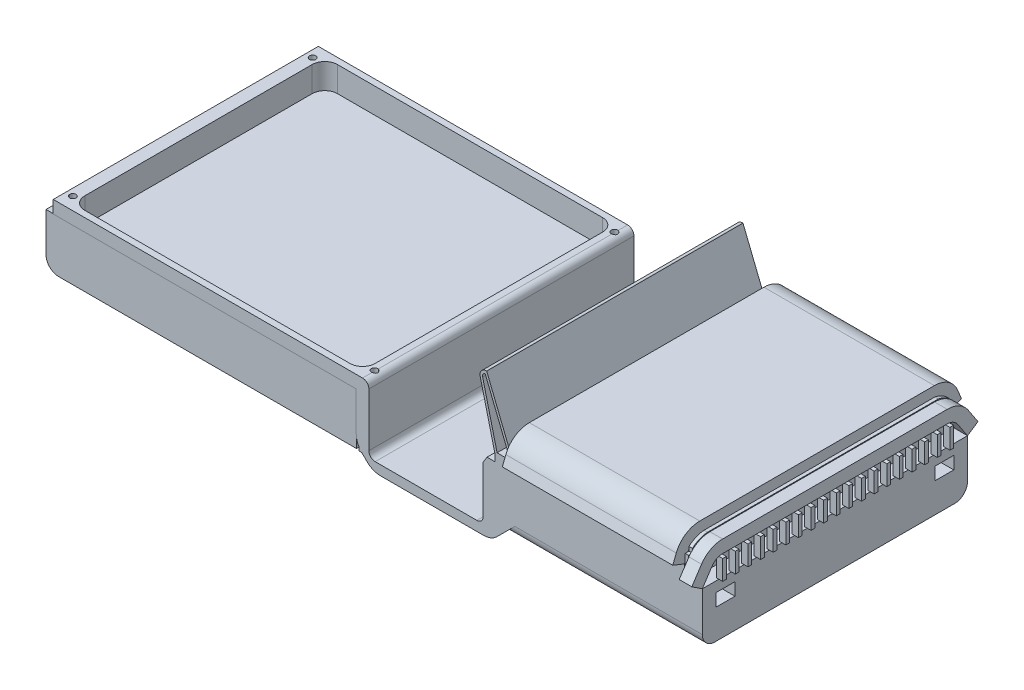
from build123d import *

# Parameters (mm, degrees)
EXTRUDE_THIN1_DEPTH       = 105
EXTRUDE_THIN2_DEPTH       = 135
SKETCH4_W                 = 210
SKETCH4_H                 = 41.464466094
BOSS_EXTRUDE1_DEPTH       = 272
SKETCH5_W                 = 99.443264673
SKETCH5_H                 = 42.373164523
CUT_EXTRUDE1_DEPTH        = 709
SKETCH6_W                 = 15
SKETCH6_H                 = 10
CUT_EXTRUDE3_DEPTH        = 10
BOSS_EXTRUDE12_DEPTH      = 203
EXTRUDE_THIN4_DEPTH       = 10
SKETCH11_W                = 2.941631748
SKETCH11_H                = 15.671312496
BOSS_EXTRUDE13_DEPTH      = 3
BOSS_EXTRUDE13_DEPTH_BACK = 2
SKETCH12_W                = 2.712469745
SKETCH12_H                = 25.887710017
BOSS_EXTRUDE16_DEPTH      = 210
CUT_EXTRUDE5_DEPTH        = 3
SKETCH14_W                = 2.712469745
SKETCH14_H                = 8.420422182
CUT_EXTRUDE6_DEPTH        = 3
CUT_EXTRUDE7_DEPTH        = 3
SKETCH16_W                = 2.712469745
SKETCH16_H                = 10.378010017
CUT_EXTRUDE8_DEPTH        = 3
BOSS_EXTRUDE17_DEPTH      = 209
FILLET1_R                 = 10
FILLET2_R                 = 10
SKETCH20_W                = 209.727383772
SKETCH20_H                = 41.060074577
BOSS_EXTRUDE18_DEPTH      = 246
FILLET3_R                 = 10
CUT_EXTRUDE9_DEPTH        = 20
FILLET4_R                 = 5
FILLET5_R                 = 5
FILLET6_R                 = 5
SKETCH24_R                = 2.5
CUT_EXTRUDE12_DEPTH       = 15


with BuildPart() as part:
    # Sketch1 → Extrude-Thin1 (new body, symmetric)
    with BuildSketch(Plane.XY):
        with BuildLine():
            Line((-242.134236503, 0), (7.865763497, 0))
            Line((7.865763497, 0), (7.865763497, -40.857864376))
            ThreePointArc((7.865763497, -40.857864376), (8.246365835, -42.771281538), (9.330229591, -44.393398282))
            Line((9.330229591, -44.393398282), (13.472365215, -48.535533906))
            ThreePointArc((13.472365215, -48.535533906), (15.094481959, -49.619397663), (17.007899121, -50))
            Line((17.007899121, -50), (98.723627874, -50))
            ThreePointArc((98.723627874, -50), (100.637045035, -49.619397663), (102.25916178, -48.535533906))
            Line((102.25916178, -48.535533906), (106.401297403, -44.393398282))
            ThreePointArc((106.401297403, -44.393398282), (107.48516116, -42.771281538), (107.865763497, -40.857864376))
            Line((107.865763497, -40.857864376), (107.865763497, 0))
            Line((107.865763497, 0), (257.865763497, 0))
            Line((257.865763497, 0), (257.865763497, -10))
            Line((257.865763497, -10), (117.865763497, -10))
            Line((117.865763497, -10), (117.865763497, -40.857864376))
            ThreePointArc((117.865763497, -40.857864376), (116.723956485, -46.598115862), (113.472365215, -51.464466094))
            Line((113.472365215, -51.464466094), (109.330229591, -55.606601718))
            ThreePointArc((109.330229591, -55.606601718), (104.463879359, -58.858192988), (98.723627874, -60))
            Line((98.723627874, -60), (17.007899121, -60))
            ThreePointArc((17.007899121, -60), (11.267647636, -58.858192988), (6.401297403, -55.606601718))
            Line((6.401297403, -55.606601718), (2.25916178, -51.464466094))
            ThreePointArc((2.25916178, -51.464466094), (-0.99242949, -46.598115862), (-2.134236503, -40.857864376))
            Line((-2.134236503, -40.857864376), (-2.134236503, -10))
            Line((-2.134236503, -10), (-242.134236503, -10))
            Line((-242.134236503, -10), (-242.134236503, 0))
        make_face()
    extrude(amount=EXTRUDE_THIN1_DEPTH, both=True)

    # Sketch4 → Boss-Extrude1 (add)
    with BuildSketch(Plane(origin=(0, 0, 0), x_dir=(0, 0, -1), z_dir=(1, 0, 0))):
        with Locations((0, -30.732233047)):
            Rectangle(SKETCH4_W, SKETCH4_H)
    extrude(amount=BOSS_EXTRUDE1_DEPTH)

    # Sketch5 → Cut-Extrude1 (cut)
    with BuildSketch(Plane.XY.offset(105)):
        with Locations((57.587395834, -31.186582261)):
            Rectangle(SKETCH5_W, SKETCH5_H)
    extrude(amount=-CUT_EXTRUDE1_DEPTH, mode=Mode.SUBTRACT)

    # Sketch6 → Cut-Extrude3 (cut)
    with BuildSketch(Plane(origin=(272, 0, 0), x_dir=(0, 0, -1), z_dir=(1, 0, 0))):
        with Locations((86.644406448, -23.03734916)):
            Rectangle(SKETCH6_W, SKETCH6_H)
        with Locations((-86.644406448, -23.03734916)):
            Rectangle(SKETCH6_W, SKETCH6_H)
    extrude(amount=-CUT_EXTRUDE3_DEPTH, mode=Mode.SUBTRACT)

    # Sketch9 → Boss-Extrude12 (add)
    with BuildSketch(Plane.XY.offset(105)):
        with BuildLine():
            Line((107.865763497, 0), (96.048468915, 47.715480872))
            ThreePointArc((96.048468915, 47.715480872), (96.964203042, 51.998873018), (100.901839983, 53.917474745))
            Line((100.901839983, 53.917474745), (101.189118197, 53.917474745))
            Line((101.189118197, 53.917474745), (122.865763497, 0))
            Line((122.865763497, 0), (107.865763497, 0))
        make_face()
        with BuildLine():
            Line((99.905994759, 51.747367373), (119.906116097, 2))
            Line((119.906116097, 2), (109.430863744, 2))
            Line((109.430863744, 2), (97.989817342, 48.196278421))
            ThreePointArc((97.989817342, 48.196278421), (98.261685442, 50.342109435), (99.905994759, 51.747367373))
        make_face(mode=Mode.SUBTRACT)
    extrude(amount=-BOSS_EXTRUDE12_DEPTH)

    # Sketch11 → Boss-Extrude13 (add, two sides)
    with BuildSketch(Plane(origin=(272, 0, 0), x_dir=(0, 0, -1), z_dir=(1, 0, 0))) as boss_extrude13_sk:
        with Locations((-90.432731373, -2.164343752)):
            Rectangle(SKETCH11_W, SKETCH11_H)
        with Locations((-80.432731373, -2.164343752)):
            Rectangle(SKETCH11_W, SKETCH11_H)
        with Locations((-70.432731373, -2.164343752)):
            Rectangle(SKETCH11_W, SKETCH11_H)
        with Locations((-60.432731373, -2.164343752)):
            Rectangle(SKETCH11_W, SKETCH11_H)
        with Locations((-50.432731373, -2.164343752)):
            Rectangle(SKETCH11_W, SKETCH11_H)
        with Locations((-40.432731373, -2.164343752)):
            Rectangle(SKETCH11_W, SKETCH11_H)
        with Locations((-30.432731373, -2.164343752)):
            Rectangle(SKETCH11_W, SKETCH11_H)
        with Locations((-20.432731373, -2.164343752)):
            Rectangle(SKETCH11_W, SKETCH11_H)
        with Locations((-10.432731373, -2.164343752)):
            Rectangle(SKETCH11_W, SKETCH11_H)
        with Locations((-0.432731373, -2.164343752)):
            Rectangle(SKETCH11_W, SKETCH11_H)
        with Locations((9.567268627, -2.164343752)):
            Rectangle(SKETCH11_W, SKETCH11_H)
        with Locations((19.567268627, -2.164343752)):
            Rectangle(SKETCH11_W, SKETCH11_H)
        with Locations((29.567268627, -2.164343752)):
            Rectangle(SKETCH11_W, SKETCH11_H)
        with Locations((39.567268627, -2.164343752)):
            Rectangle(SKETCH11_W, SKETCH11_H)
        with Locations((49.567268627, -2.164343752)):
            Rectangle(SKETCH11_W, SKETCH11_H)
        with Locations((59.567268627, -2.164343752)):
            Rectangle(SKETCH11_W, SKETCH11_H)
        with Locations((69.567268627, -2.164343752)):
            Rectangle(SKETCH11_W, SKETCH11_H)
        with Locations((79.567268627, -2.164343752)):
            Rectangle(SKETCH11_W, SKETCH11_H)
        with Locations((89.567268627, -2.164343752)):
            Rectangle(SKETCH11_W, SKETCH11_H)
    extrude(amount=BOSS_EXTRUDE13_DEPTH)
    extrude(boss_extrude13_sk.sketch, amount=-BOSS_EXTRUDE13_DEPTH_BACK)

    # Sketch12 → Boss-Extrude16 (add)
    with BuildSketch(Plane.XY.offset(105)):
        with Locations((259.776090298, 2.943855009)):
            Rectangle(SKETCH12_W, SKETCH12_H)
    extrude(amount=-BOSS_EXTRUDE16_DEPTH)

    # Sketch13 → Cut-Extrude5 (cut)
    with BuildSketch(Plane(origin=(261.132325171, 0, 0), x_dir=(0, 0, -1), z_dir=(1, 0, 0))):
        with BuildLine():
            Line((-104.850011927, 15.887710017), (-105, 7.467287835))
            ThreePointArc((-105, 7.467287835), (-98.448050053, 13.321974048), (-90.044336726, 15.887710017))
            Line((-90.044336726, 15.887710017), (-104.850011927, 15.887710017))
        make_face()
    extrude(amount=-CUT_EXTRUDE5_DEPTH, mode=Mode.SUBTRACT)

    # Sketch14 → Cut-Extrude6 (cut)
    with BuildSketch(Plane.XY.offset(105)):
        with Locations((259.776090298, 11.677498926)):
            Rectangle(SKETCH14_W, SKETCH14_H)
    extrude(amount=-CUT_EXTRUDE6_DEPTH, mode=Mode.SUBTRACT)

    # Sketch15 → Cut-Extrude7 (cut)
    with BuildSketch(Plane(origin=(261.132325171, 0, 0), x_dir=(0, 0, -1), z_dir=(1, 0, 0))):
        with BuildLine():
            Line((105, 15.887710017), (92.724195151, 15.887710017))
            ThreePointArc((92.724195151, 15.887710017), (99.535881147, 13.154831825), (104.921037717, 8.16807155))
            Line((104.921037717, 8.16807155), (105, 15.887710017))
        make_face()
    extrude(amount=-CUT_EXTRUDE7_DEPTH, mode=Mode.SUBTRACT)

    # Sketch16 → Cut-Extrude8 (cut)
    with BuildSketch(Plane(origin=(0, 0, -105), x_dir=(-1, 0, 0), z_dir=(0, 0, -1))):
        with Locations((-259.776090298, 10.698705009)):
            Rectangle(SKETCH16_W, SKETCH16_H)
    extrude(amount=-CUT_EXTRUDE8_DEPTH, mode=Mode.SUBTRACT)

    # Sketch19 → Boss-Extrude17 (add)
    with BuildSketch(Plane.XY.offset(105)):
        Polygon((107.865763497, -5), (101.446114683, -5), (98.359197237, -10), (98.359197237, -52.373164523), (107.30902817, -52.373164523), (107.30902817, -10), (107.865763497, -10), align=None)
    extrude(amount=-BOSS_EXTRUDE17_DEPTH)

    # Fillet1
    fillet1_edges = [part.edges().sort_by_distance(p)[0] for p in [
        (192.736182608, -51.464466094, 105),
    ]]
    fillet(fillet1_edges, radius=FILLET1_R)

    # Fillet2
    fillet2_edges = [part.edges().sort_by_distance(p)[0] for p in [
        (192.736182608, -51.464466094, -105),
    ]]
    fillet(fillet2_edges, radius=FILLET2_R)

    # Sketch20 → Boss-Extrude18 (add)
    with BuildSketch(Plane.ZY.offset(2.134236503)):
        with Locations((-0.136308114, -30.530037289)):
            Rectangle(SKETCH20_W, SKETCH20_H)
    extrude(amount=BOSS_EXTRUDE18_DEPTH)

    # Fillet3
    fillet3_edges = [part.edges().sort_by_distance(p)[0] for p in [
        (-248.134236503, -51.060074577, -0.136308114),
    ]]
    fillet(fillet3_edges, radius=FILLET3_R)

    # Sketch21 → Cut-Extrude9 (cut)
    with BuildSketch(Plane(origin=(0, 0, 0), x_dir=(1, 0, 0), z_dir=(0, 1, 0))):
        with BuildLine():
            Line((-222.134236503, 100.100279687), (-12.134236503, 100.100279687))
            ThreePointArc((-12.134236503, 100.100279687), (-5.063168691, 97.171347499), (-2.134236503, 90.100279687))
            Line((-2.134236503, 90.100279687), (-2.134236503, -90))
            ThreePointArc((-2.134236503, -90), (-5.063168691, -97.071067812), (-12.134236503, -100))
            Line((-12.134236503, -100), (-222.134236503, -100))
            ThreePointArc((-222.134236503, -100), (-229.205304315, -97.071067812), (-232.134236503, -90))
            Line((-232.134236503, -90), (-232.134236503, 90.100279687))
            ThreePointArc((-232.134236503, 90.100279687), (-229.205304315, 97.171347499), (-222.134236503, 100.100279687))
        make_face()
    extrude(amount=-CUT_EXTRUDE9_DEPTH, mode=Mode.SUBTRACT)

    # Fillet4
    fillet4_edges = [part.edges().sort_by_distance(p)[0] for p in [
        (7.865763497, 0, 0),
    ]]
    fillet(fillet4_edges, radius=FILLET4_R)

    # Fillet5
    fillet5_edges = [part.edges().sort_by_distance(p)[0] for p in [
        (7.865763497, -52.373164523, 0),
    ]]
    fillet(fillet5_edges, radius=FILLET5_R)

    # Fillet6
    fillet6_edges = [part.edges().sort_by_distance(p)[0] for p in [
        (98.359197237, -52.373164523, 0.5),
    ]]
    fillet(fillet6_edges, radius=FILLET6_R)

    # Sketch24 → Cut-Extrude12 (cut)
    with BuildSketch(Plane(origin=(0, 0, 0), x_dir=(1, 0, 0), z_dir=(0, 1, 0))):
        with Locations((-236.634236503, -95)):
            Circle(SKETCH24_R)
        with Locations((-236.634236503, 95)):
            Circle(SKETCH24_R)
        with Locations((2.365763497, 95)):
            Circle(SKETCH24_R)
        with Locations((2.365763497, -95)):
            Circle(SKETCH24_R)
    extrude(amount=-CUT_EXTRUDE12_DEPTH, mode=Mode.SUBTRACT)


with BuildPart() as body_2:
    # Sketch3 → Extrude-Thin2 (new body)
    with BuildSketch(Plane(origin=(257.865763497, 0, 0), x_dir=(0, 0, -1), z_dir=(1, 0, 0))):
        with BuildLine():
            Line((-105, 0), (-102.214164536, 7.031622761))
            ThreePointArc((-102.214164536, 7.031622761), (-98.537132094, 11.619732313), (-92.917223111, 13.348298156))
            Line((-92.917223111, 13.348298156), (92.917223111, 13.348298156))
            ThreePointArc((92.917223111, 13.348298156), (98.537132094, 11.619732313), (102.214164536, 7.031622761))
            Line((102.214164536, 7.031622761), (105, 0))
            Line((105, 0), (114.296941425, 3.683324605))
            Line((114.296941425, 3.683324605), (111.511105961, 10.714947366))
            ThreePointArc((111.511105961, 10.714947366), (104.157041077, 19.891166471), (92.917223111, 23.348298156))
            Line((92.917223111, 23.348298156), (-92.917223111, 23.348298156))
            ThreePointArc((-92.917223111, 23.348298156), (-104.157041077, 19.891166471), (-111.511105961, 10.714947366))
            Line((-111.511105961, 10.714947366), (-114.296941425, 3.683324605))
            Line((-114.296941425, 3.683324605), (-105, 0))
        make_face()
    extrude(amount=-EXTRUDE_THIN2_DEPTH)


with BuildPart() as body_3:
    # Sketch10 → Extrude-Thin4 (new body)
    with BuildSketch(Plane(origin=(272, 0, 0), x_dir=(0, 0, -1), z_dir=(1, 0, 0))):
        with BuildLine():
            Line((-105, -10), (-97.300963307, 1.632843776))
            ThreePointArc((-97.300963307, 1.632843776), (-93.695263464, 4.922586457), (-88.961915499, 6.113760369))
            Line((-88.961915499, 6.113760369), (88.961915499, 6.113760369))
            ThreePointArc((88.961915499, 6.113760369), (93.695263464, 4.922586457), (97.300963307, 1.632843776))
            Line((97.300963307, 1.632843776), (105, -10))
            Line((105, -10), (113.339047808, -4.480916593))
            Line((113.339047808, -4.480916593), (105.640011115, 7.151927183))
            ThreePointArc((105.640011115, 7.151927183), (98.42861143, 13.731412544), (88.961915499, 16.113760369))
            Line((88.961915499, 16.113760369), (-88.961915499, 16.113760369))
            ThreePointArc((-88.961915499, 16.113760369), (-98.42861143, 13.731412544), (-105.640011115, 7.151927183))
            Line((-105.640011115, 7.151927183), (-113.339047808, -4.480916593))
            Line((-113.339047808, -4.480916593), (-105, -10))
        make_face()
    extrude(amount=-EXTRUDE_THIN4_DEPTH)


solid = Compound([part.part, body_2.part, body_3.part])
